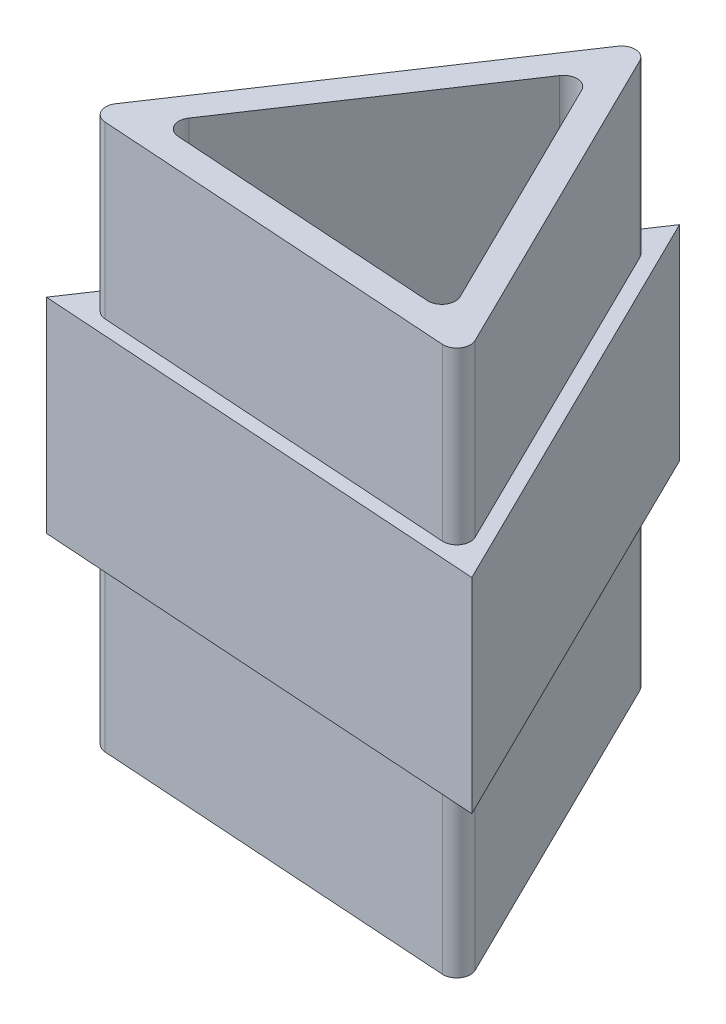
from build123d import *

# Parameters (mm, degrees)
BOSS_EXTRUDE1_DEPTH = 40
FILLET1_R           = 1
BOSS_EXTRUDE2_DEPTH = 7.5


with BuildPart() as part:
    # Sketch1 → Boss-Extrude1 (new body)
    with BuildSketch(Plane(origin=(0, 0, 0), x_dir=(1, 0, 0), z_dir=(0, 1, 0))):
        Polygon((0, 17.282938314), (-16.6777552, -7.65403186), (13.257172065, -9.628906454), align=None)
        Polygon((-0.263316613, 13.291614679), (-13.089509231, -5.886408918), (9.932242708, -7.405205761), align=None, mode=Mode.SUBTRACT)
    extrude(amount=BOSS_EXTRUDE1_DEPTH)

    # Fillet1
    fillet1_edges = [part.edges().sort_by_distance(p)[0] for p in [
        (9.932242708, 20, 7.405205761),
        (-0.263316613, 20, -13.291614679),
        (-13.089509231, 20, 5.886408918),
        (13.257172065, 20, 9.628906454),
        (-16.6777552, 20, 7.65403186),
        (0, 20, -17.282938314),
    ]]
    fillet(fillet1_edges, radius=FILLET1_R)

    # Sketch2 → Boss-Extrude2 (add, symmetric)
    with BuildSketch(Plane(origin=(0, 20, 0), x_dir=(-1, 0, 0), z_dir=(0, -1, 0))):
        Polygon((18.471878185, -8.537843331), (-14.919636743, -10.740756801), (-0.131658306, 19.278600132), align=None)
        with BuildLine():
            Line((-12.491768879, -8.075150372), (-0.765403186, 15.729182232))
            ThreePointArc((-0.765403186, 15.729182232), (0.065829153, 16.285107406), (0.962890645, 15.84320167))
            Line((0.962890645, 15.84320167), (15.714864555, -6.214295216))
            ThreePointArc((15.714864555, -6.214295216), (15.780693708, -7.212126125), (14.949461369, -7.768051298))
            Line((14.949461369, -7.768051298), (-11.528878233, -9.514887016))
            ThreePointArc((-11.528878233, -9.514887016), (-12.425939725, -9.072981281), (-12.491768879, -8.075150372))
        make_face(mode=Mode.SUBTRACT)
    extrude(amount=BOSS_EXTRUDE2_DEPTH, both=True)


solid = part.part
